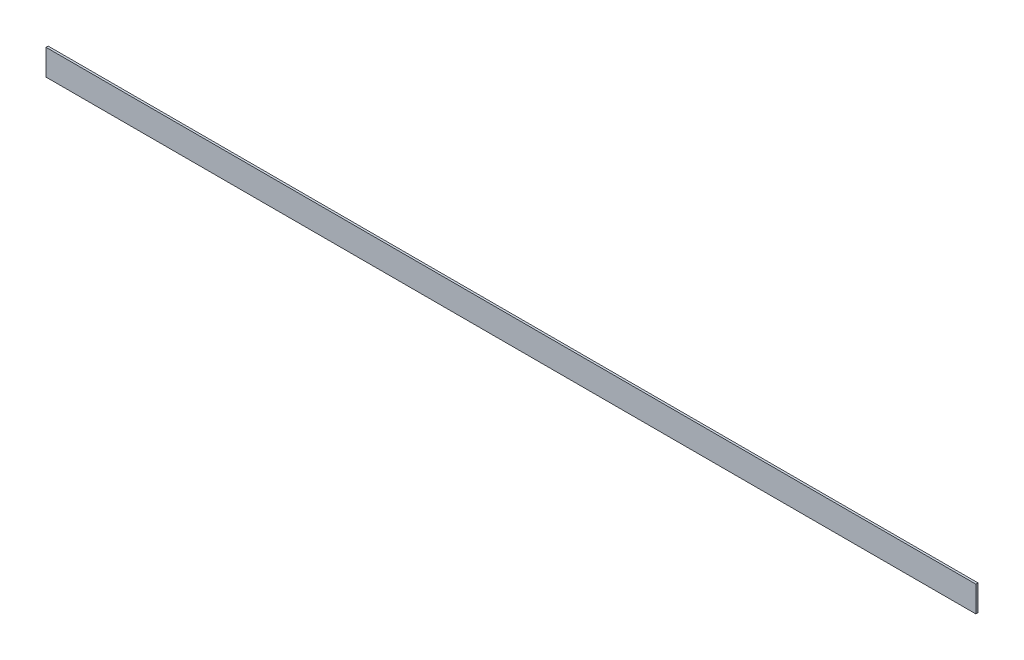
from build123d import *

# Parameters (mm, degrees)
SKETCH1_W           = 6.35
SKETCH1_H           = 76.2
BOSS_EXTRUDE1_DEPTH = 2743.2


with BuildPart() as part:
    # Sketch1 → Boss-Extrude1 (new body)
    with BuildSketch(Plane(origin=(0, 0, 0), x_dir=(0, 0, -1), z_dir=(1, 0, 0))):
        Rectangle(SKETCH1_W, SKETCH1_H)
    extrude(amount=BOSS_EXTRUDE1_DEPTH)


solid = part.part
